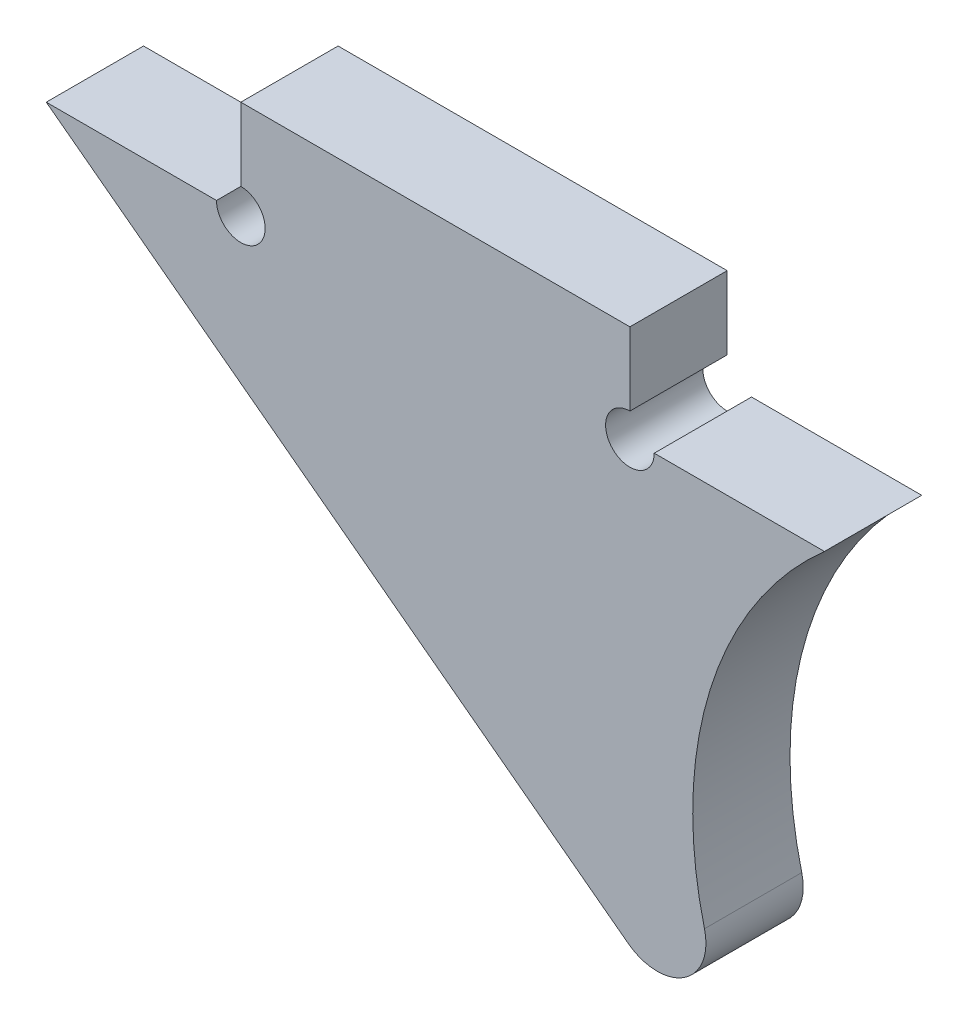
from build123d import *

# Parameters (mm, degrees)
BOSS_EXTRUDE1_DEPTH = 3.175
FILLET1_R           = 1.5875
SKETCH3_R           = 0.79375
CUT_EXTRUDE1_DEPTH  = 3.175


with BuildPart() as part:
    # Sketch2 → Boss-Extrude1 (new body)
    with BuildSketch(Plane.XY):
        with BuildLine():
            Line((-19.05, 0), (-25.4, 0))
            Line((-25.4, 0), (0.767904, -19.675721))
            ThreePointArc((0.767904, -19.675721), (-4.290078, -10.020279), (0, 0))
            Line((0, 0), (-6.35, 0))
            Line((-6.35, 0), (-6.35, 3.175))
            Line((-6.35, 3.175), (-19.05, 3.175))
            Line((-19.05, 3.175), (-19.05, 0))
        make_face()
    extrude(amount=BOSS_EXTRUDE1_DEPTH)

    # Fillet1
    fillet1_edges = [part.edges().sort_by_distance(p)[0] for p in [
        (0.767904, -19.675721, 1.5875),
    ]]
    fillet(fillet1_edges, radius=FILLET1_R)

    # Sketch3 → Cut-Extrude1 (cut)
    with BuildSketch(Plane.XY.offset(3.175)):
        with Locations((-19.05, 0)):
            Circle(SKETCH3_R)
        with Locations((-6.35, 0)):
            Circle(SKETCH3_R)
    extrude(amount=-CUT_EXTRUDE1_DEPTH, mode=Mode.SUBTRACT)


solid = part.part
